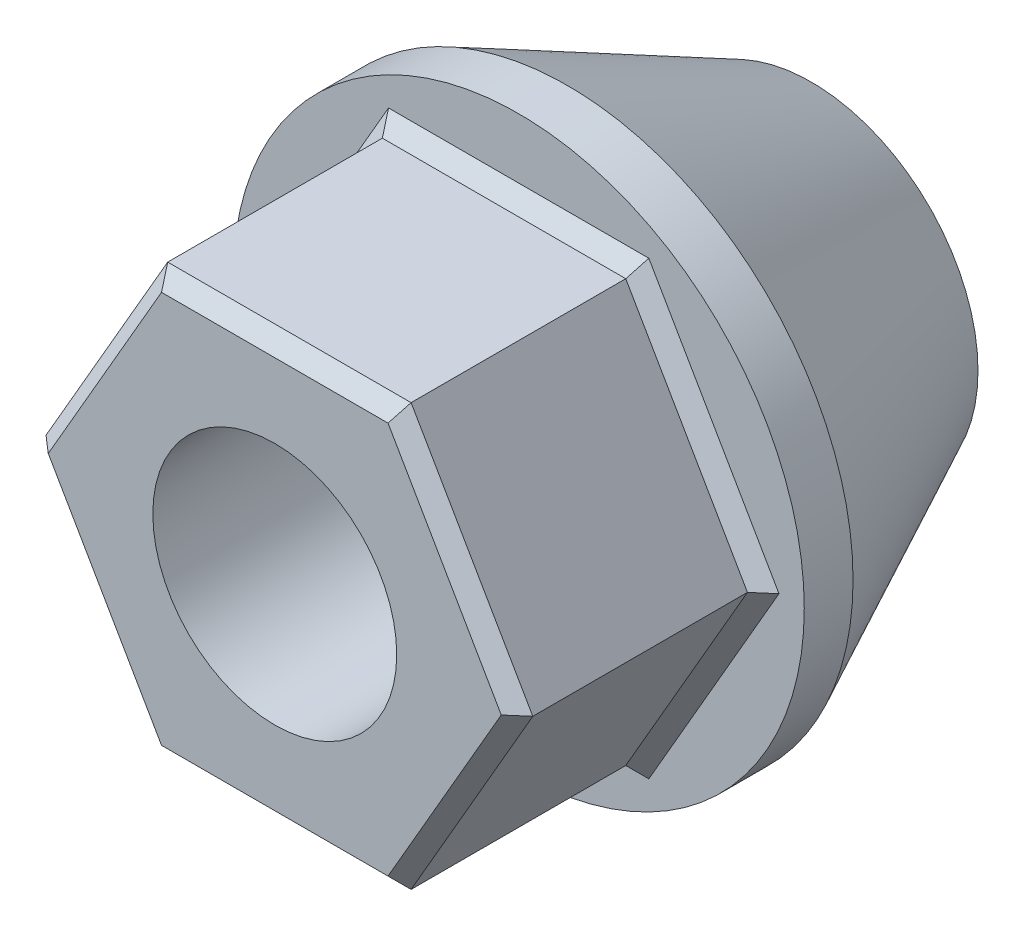
from build123d import *

# Parameters (mm, degrees)
EXTRUDE1_DEPTH     = 12.7
SKETCH3_R          = 14.869502809
EXTRUDE2_DEPTH     = 2.54
CHAMFER1_SIZE      = 0.762
CHAMFER2_SIZE      = 0.762
SKETCH5_R          = 14.869502809
EXTRUDE3_DEPTH     = 12.7
EXTRUDE3_TAPER     = 26
SKETCH4_R          = 6.35
CUT_EXTRUDE1_DEPTH = 28.9400001


with BuildPart() as part:
    # Sketch2 → Extrude1 (new body)
    with BuildSketch(Plane.XY):
        Polygon((12.673375262, 0), (6.336687631, 10.975464929), (-6.336687631, 10.975464929), (-12.673375262, 0), (-6.336687631, -10.975464929), (6.336687631, -10.975464929), align=None)
    extrude(amount=EXTRUDE1_DEPTH)

    # Sketch3 → Extrude2 (add)
    with BuildSketch(Plane(origin=(0, 0, 0), x_dir=(-1, 0, 0), z_dir=(0, 0, -1))):
        Circle(SKETCH3_R)
    extrude(amount=EXTRUDE2_DEPTH)

    # Chamfer1
    chamfer1_edges = [part.edges().sort_by_distance(p)[0] for p in [
        (0, -10.975464929, 0),
        (-9.505031447, -5.487732464, 0),
        (-9.505031447, 5.487732464, 0),
        (0, 10.975464929, 0),
        (9.505031447, 5.487732464, 0),
        (9.505031447, -5.487732464, 0),
    ]]
    chamfer(chamfer1_edges, length=CHAMFER1_SIZE)

    # Chamfer2
    chamfer2_edges = [part.edges().sort_by_distance(p)[0] for p in [
        (0, 10.975464929, 12.7),
        (-9.505031447, 5.487732464, 12.7),
        (-9.505031447, -5.487732464, 12.7),
        (0, -10.975464929, 12.7),
        (9.505031447, -5.487732464, 12.7),
        (9.505031447, 5.487732464, 12.7),
    ]]
    chamfer(chamfer2_edges, length=CHAMFER2_SIZE)

    # Sketch5 → Extrude3 (add)
    with BuildSketch(Plane(origin=(0, 0, -2.54), x_dir=(-1, 0, 0), z_dir=(0, 0, -1))):
        Circle(SKETCH5_R)
    extrude(amount=EXTRUDE3_DEPTH, taper=EXTRUDE3_TAPER)

    # Sketch4 → Cut-Extrude1 (cut, through all)
    with BuildSketch(Plane.XY.offset(12.7)):
        Circle(SKETCH4_R)
    extrude(amount=-CUT_EXTRUDE1_DEPTH, mode=Mode.SUBTRACT)


solid = part.part
